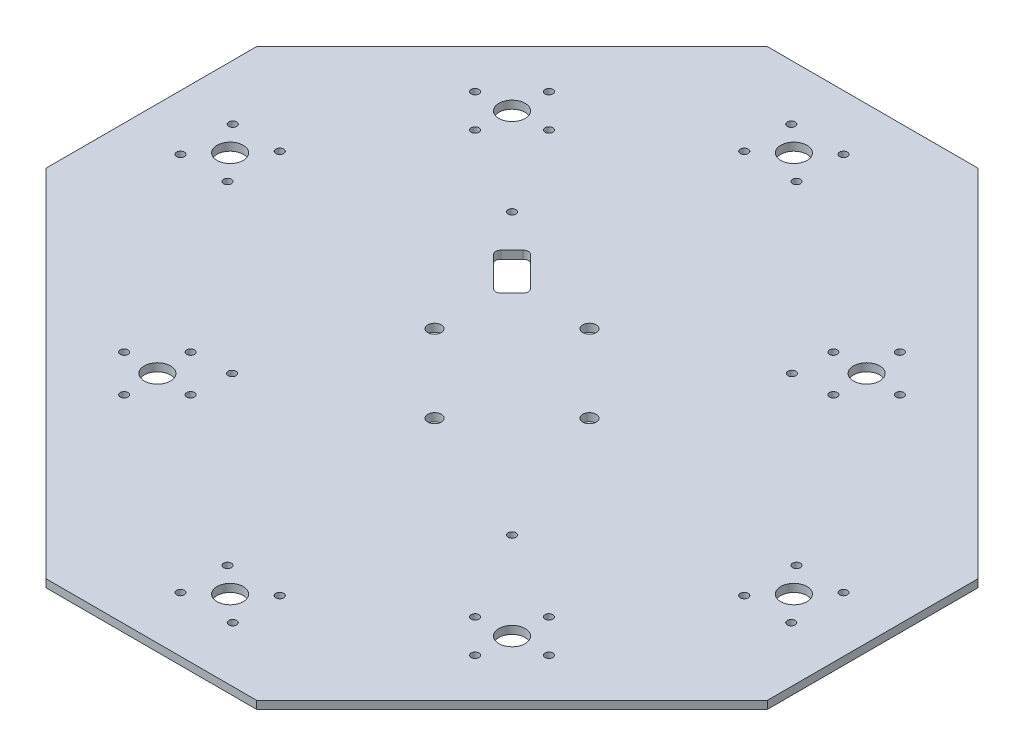
from build123d import *

# Parameters (mm, degrees)
BOSS_EXTRUDE2_DEPTH                  = 3
F_13_64_0_20313_DIAMETER_HOLE1_D     = 5.159502
F_13_64_0_20313_DIAMETER_HOLE1_DEPTH = 3
CUT_EXTRUDE1_DEPTH                   = 4
FILLET2_R                            = 2
FILLET3_R                            = 2
FILLET4_R                            = 2
FILLET5_R                            = 2
F_3_0MM_DOWEL_HOLE1_D                = 3
F_3_0MM_DOWEL_HOLE1_DEPTH            = 3
F_10_0MM_DOWEL_HOLE1_D               = 10
F_10_0MM_DOWEL_HOLE1_DEPTH           = 3
F_10_0MM_DOWEL_HOLE2_D               = 10
F_10_0MM_DOWEL_HOLE2_DEPTH           = 3
F_3_0MM_DOWEL_HOLE2_D                = 3
F_3_0MM_DOWEL_HOLE2_DEPTH            = 3


with BuildPart() as part:
    # Sketch3 → Boss-Extrude2 (new body)
    with BuildSketch(Plane(origin=(0, 0, 0), x_dir=(1, 0, 0), z_dir=(0, 1, 0))):
        Polygon((146.917568262, 30.566233816), (11.506619665, 165.977182413), (-68.75, 165.977182413), (-165.977182413, 68.75), (-165.977182413, -11.506619665), (-30.566233816, -146.917568262), (49.690385849, -146.917568262), (146.917568262, -49.690385849), align=None)
    extrude(amount=BOSS_EXTRUDE2_DEPTH)

    # 13/64 (0.20313) Diameter Hole1
    with Locations(Plane(origin=(0, 0, 0), x_dir=(-1, 0, 0), z_dir=(0, -1, 0))):
        with Locations((39.029807033, 9.528212544), (9.528212544, -19.970192881), (-19.970192881, 9.531401607), (9.531401607, 39.029807033)):
            Hole(F_13_64_0_20313_DIAMETER_HOLE1_D / 2, depth=F_13_64_0_20313_DIAMETER_HOLE1_DEPTH)

    # Sketch12 → Cut-Extrude1 (cut, through all)
    with BuildSketch(Plane.XZ):
        Polygon((-36.04631137, -36.04631137), (-39.581845276, -32.510777464), (-53.7239809, -46.652913088), (-46.652913088, -53.7239809), (-32.510777464, -39.581845276), align=None)
    extrude(amount=-CUT_EXTRUDE1_DEPTH, mode=Mode.SUBTRACT)

    # Fillet2
    fillet2_edges = [part.edges().sort_by_distance(p)[0] for p in [
        (-39.581845276, 1.5, -32.510777464),
    ]]
    fillet(fillet2_edges, radius=FILLET2_R)

    # Fillet3
    fillet3_edges = [part.edges().sort_by_distance(p)[0] for p in [
        (-32.510777464, 1.5, -39.581845276),
    ]]
    fillet(fillet3_edges, radius=FILLET3_R)

    # Fillet4
    fillet4_edges = [part.edges().sort_by_distance(p)[0] for p in [
        (-53.7239809, 1.5, -46.652913088),
    ]]
    fillet(fillet4_edges, radius=FILLET4_R)

    # Fillet5
    fillet5_edges = [part.edges().sort_by_distance(p)[0] for p in [
        (-46.652913088, 1.5, -53.7239809),
    ]]
    fillet(fillet5_edges, radius=FILLET5_R)

    # Ø3.0mm Dowel Hole1
    with Locations(Plane(origin=(0, 0, 0), x_dir=(-1, 0, 0), z_dir=(0, -1, 0))):
        with Locations((-76.383242623, -90.45627663), (-90.453906961, -76.384091118), (-77.79601145, -63.7275639), (-63.725347112, -77.799749412), (-19.512076016, -125.867568262), (-19.512076016, -107.967568262), (0.387923984, -125.867568262), (0.387923984, -107.967568262), (63.695294959, -58.704128358), (76.351822177, -71.362023869), (90.42400769, -57.291359531), (77.767480471, -44.63346402), (144.927182413, 38.571690168), (127.027182413, 38.571690168), (127.027182413, 18.671690168), (144.927182413, 18.671690168), (96.855625588, 82.78717805), (82.784961264, 96.859363576), (95.442856787, 109.515890782), (109.513521111, 95.443705257), (18.671690168, 144.927182413), (18.671690168, 127.027182413), (38.571690168, 127.027182413), (38.571690168, 144.927182413), (-58.70786632, 63.693078171), (-71.364393538, 76.350973682), (-44.635680808, 77.763742509), (-57.292208026, 90.42163802), (-125.867568262, -19.512076016), (-107.967568262, -19.512076016), (-107.967568262, 0.387923984), (-125.867568262, 0.387923984)):
            Hole(F_3_0MM_DOWEL_HOLE1_D / 2, depth=F_3_0MM_DOWEL_HOLE1_DEPTH)

    # Ø10.0mm Dowel Hole1
    with Locations(Plane(origin=(0, 3, 0), x_dir=(1, 0, 0), z_dir=(0, 1, 0))):
        with Locations((-135.977182413, 28.621690168), (-96.149241188, 96.151534416), (-28.621690168, 135.977182413), (58.000037173, 77.057358096), (116.917568262, -9.562076016)):
            Hole(F_10_0MM_DOWEL_HOLE1_D / 2, depth=F_10_0MM_DOWEL_HOLE1_DEPTH)

    # Ø10.0mm Dowel Hole2
    with Locations(Plane(origin=(0, 3, 0), x_dir=(1, 0, 0), z_dir=(0, 1, 0))):
        with Locations((9.562076016, -116.917568262), (77.089627036, -77.091920265), (-77.059651324, -57.997743944)):
            Hole(F_10_0MM_DOWEL_HOLE2_D / 2, depth=F_10_0MM_DOWEL_HOLE2_DEPTH)

    # Ø3.0mm Dowel Hole2
    with Locations(Plane(origin=(0, 0, 0), x_dir=(-1, 0, 0), z_dir=(0, -1, 0))):
        with Locations((62.825395525, -43.770951614), (-43.770951614, -43.765781374), (62.830565765, 62.825395525), (-43.765781374, 62.830565765)):
            Hole(F_3_0MM_DOWEL_HOLE2_D / 2, depth=F_3_0MM_DOWEL_HOLE2_DEPTH)


solid = part.part
